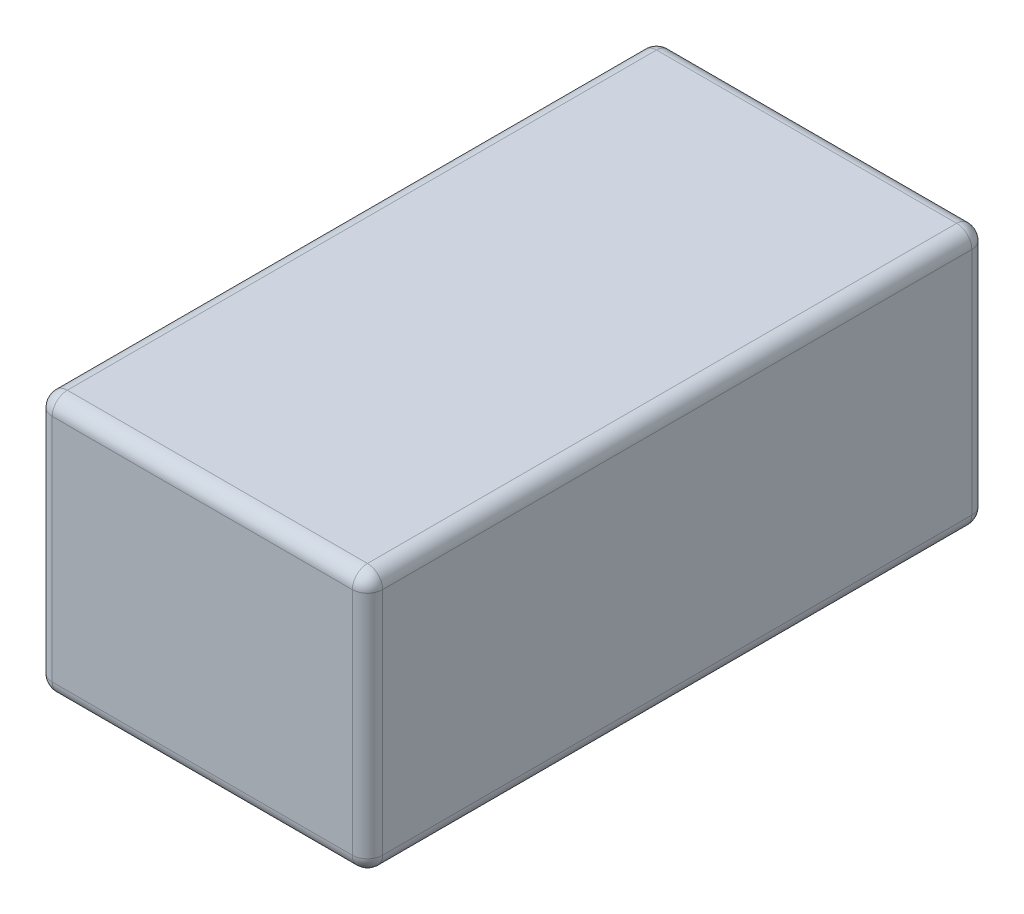
from build123d import *

# Parameters (mm, degrees)
SKETCH1_W           = 83.185
SKETCH1_H           = 155.956
BOSS_EXTRUDE1_DEPTH = 65.532
FILLET1_R           = 3.81


with BuildPart() as part:
    # Sketch1 → Boss-Extrude1 (new body)
    with BuildSketch(Plane(origin=(0, 0, 0), x_dir=(1, 0, 0), z_dir=(0, 1, 0))):
        Rectangle(SKETCH1_W, SKETCH1_H)
    extrude(amount=BOSS_EXTRUDE1_DEPTH)

    # Fillet1
    fillet1_edges = [part.edges().sort_by_distance(p)[0] for p in [
        (-41.5925, 65.532, 0),
        (0, 65.532, 77.978),
        (41.5925, 65.532, 0),
        (0, 0, 77.978),
        (-41.5925, 0, 0),
        (0, 0, -77.978),
        (41.5925, 0, 0),
        (41.5925, 32.766, 77.978),
        (-41.5925, 32.766, 77.978),
        (-41.5925, 32.766, -77.978),
        (41.5925, 32.766, -77.978),
        (0, 65.532, -77.978),
    ]]
    fillet(fillet1_edges, radius=FILLET1_R)


solid = part.part
